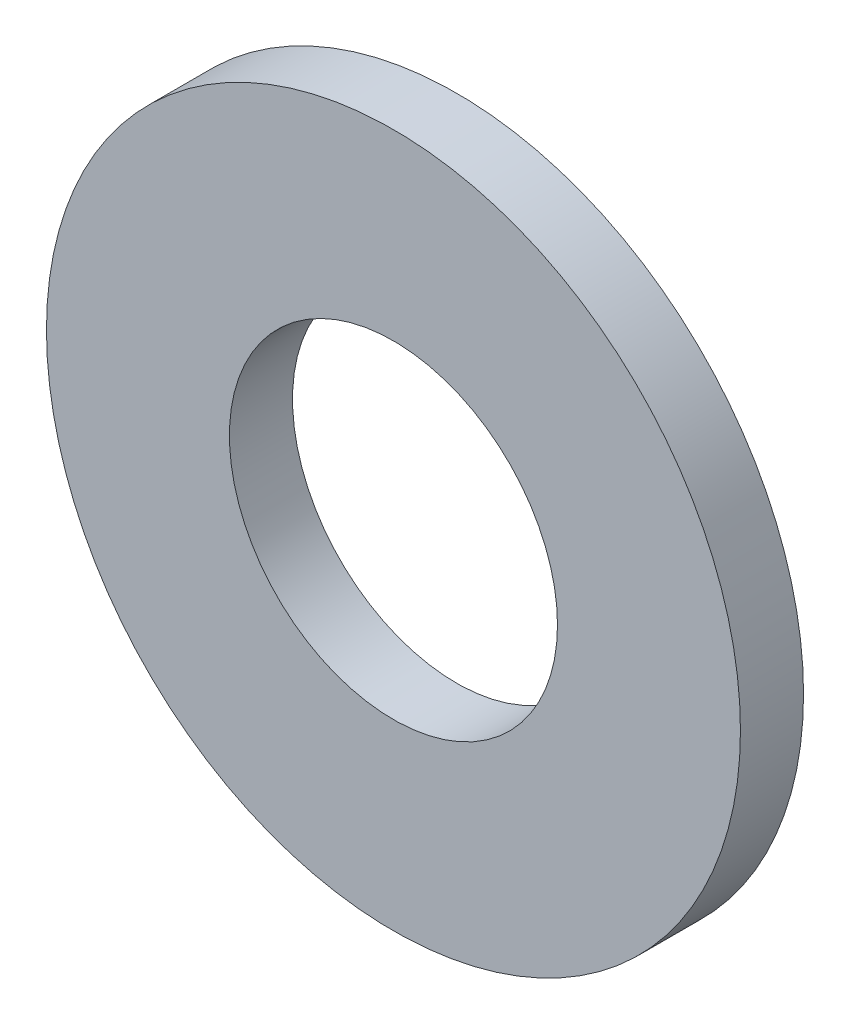
from build123d import *

# Parameters (mm, degrees)
SKETCH1_R           = 5.5
SKETCH1_R_2         = 2.6
BOSS_EXTRUDE1_DEPTH = 1


with BuildPart() as part:
    # Sketch1 → Boss-Extrude1 (new body)
    with BuildSketch(Plane.XY):
        Circle(SKETCH1_R)
        Circle(SKETCH1_R_2, mode=Mode.SUBTRACT)
    extrude(amount=BOSS_EXTRUDE1_DEPTH)


solid = part.part
